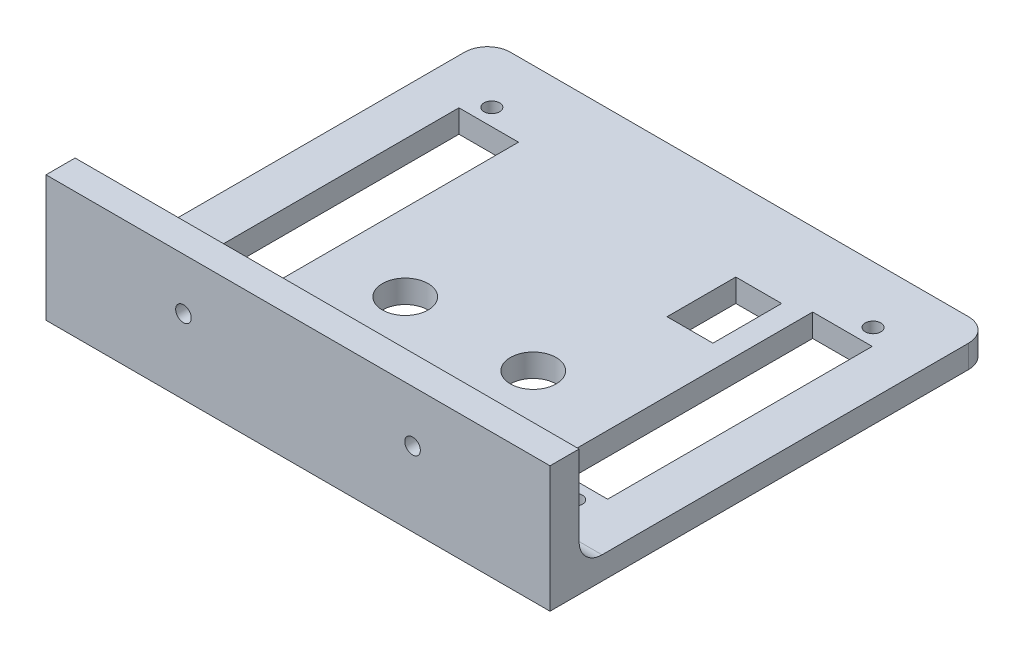
from build123d import *

# Parameters (mm, degrees)
SKETCH1_W                      = 110
SKETCH1_H                      = 90
BOSS_EXTRUDE1_DEPTH            = 2.5
M3_CLEARANCE_HOLE1_D           = 3.4
M3_CLEARANCE_HOLE1_DEPTH       = 5
SKETCH5_W                      = 110
SKETCH5_H                      = 6.35
BOSS_EXTRUDE2_DEPTH            = 25
BOSS_EXTRUDE2_DEPTH_BACK       = 2.5
CBORE_FOR_M3_SHCS1_D           = 3.4
CBORE_FOR_M3_SHCS1_DEPTH       = 6.35
CBORE_FOR_M3_SHCS1_CBORE_D     = 6.5
CBORE_FOR_M3_SHCS1_CBORE_DEPTH = 3
CUT_EXTRUDE1_DEPTH             = 6
SKETCH10_W                     = 74.2
SKETCH10_H                     = 70.2
SKETCH10_R                     = 5
SKETCH10_W_2                   = 10
SKETCH10_H_2                   = 15
BOSS_EXTRUDE4_DEPTH            = 5
SKETCH11_W                     = 5
SKETCH11_H                     = 57.74767184
CUT_EXTRUDE2_DEPTH             = 6
FILLET1_R                      = 5


with BuildPart() as part:
    # Sketch1 → Boss-Extrude1 (new body, symmetric)
    with BuildSketch(Plane(origin=(0, 0, 0), x_dir=(1, 0, 0), z_dir=(0, 1, 0))):
        with Locations((55, -45)):
            Rectangle(SKETCH1_W, SKETCH1_H)
    extrude(amount=BOSS_EXTRUDE1_DEPTH, both=True)

    # M3 Clearance Hole1
    with Locations(Plane(origin=(0, 2.5, 0), x_dir=(1, 0, 0), z_dir=(0, 1, 0))):
        with Locations((13.4, -77.55755), (96.6, -12.44245), (96.6, -77.55755), (13.4, -12.44245)):
            Hole(M3_CLEARANCE_HOLE1_D / 2, depth=M3_CLEARANCE_HOLE1_DEPTH)

    # Sketch5 → Boss-Extrude2 (add, two sides)
    with BuildSketch(Plane(origin=(0, 0, 0), x_dir=(1, 0, 0), z_dir=(0, 1, 0))) as boss_extrude2_sk:
        with Locations((55, -93.175)):
            Rectangle(SKETCH5_W, SKETCH5_H)
    extrude(amount=BOSS_EXTRUDE2_DEPTH)
    extrude(boss_extrude2_sk.sketch, amount=-BOSS_EXTRUDE2_DEPTH_BACK)

    # CBORE for M3 SHCS1
    with Locations(Plane(origin=(0, 0, 90), x_dir=(-1, 0, 0), z_dir=(0, 0, -1))):
        with Locations((-80, 13.75), (-30, 13.75)):
            CounterBoreHole(CBORE_FOR_M3_SHCS1_D / 2, CBORE_FOR_M3_SHCS1_CBORE_D / 2, CBORE_FOR_M3_SHCS1_CBORE_DEPTH, depth=CBORE_FOR_M3_SHCS1_DEPTH)

    # Sketch8 → Cut-Extrude1 (cut, through all)
    with BuildSketch(Plane(origin=(0, 2.5, 0), x_dir=(1, 0, 0), z_dir=(0, 1, 0))):
        Polygon((17.9, -9.9), (92.1, -9.9), (92.1, -16.12616408), (100.1, -16.12616408), (100.1, -73.87383592), (92.1, -73.87383592), (92.1, -80.1), (17.9, -80.1), (17.9, -73.87383592), (9.9, -73.87383592), (9.9, -16.12616408), (17.9, -16.12616408), align=None)
    extrude(amount=-CUT_EXTRUDE1_DEPTH, mode=Mode.SUBTRACT)

    # Sketch10 → Boss-Extrude4 (add, through all)
    with BuildSketch(Plane(origin=(0, 2.5, 0), x_dir=(1, 0, 0), z_dir=(0, 1, 0))):
        with Locations((55, -45)):
            Rectangle(SKETCH10_W, SKETCH10_H)
        with Locations((39.76, -57.70755)):
            Circle(SKETCH10_R, mode=Mode.SUBTRACT)
        with Locations((67.7, -57.70755)):
            Circle(SKETCH10_R, mode=Mode.SUBTRACT)
        with Locations((77.1, -25.4)):
            Rectangle(SKETCH10_W_2, SKETCH10_H_2, mode=Mode.SUBTRACT)
    extrude(amount=-BOSS_EXTRUDE4_DEPTH)

    # Sketch11 → Cut-Extrude2 (cut, through all)
    with BuildSketch(Plane(origin=(0, 2.5, 0), x_dir=(1, 0, 0), z_dir=(0, 1, 0))):
        with Locations((20.4, -45)):
            Rectangle(SKETCH11_W, SKETCH11_H)
        with Locations((89.6, -45)):
            Rectangle(SKETCH11_W, SKETCH11_H)
    extrude(amount=-CUT_EXTRUDE2_DEPTH, mode=Mode.SUBTRACT)

    # Fillet1
    fillet1_edges = [part.edges().sort_by_distance(p)[0] for p in [
        (0, 0, 0),
        (110, 0, 0),
        (55, 2.5, 90),
    ]]
    fillet(fillet1_edges, radius=FILLET1_R)


solid = part.part
